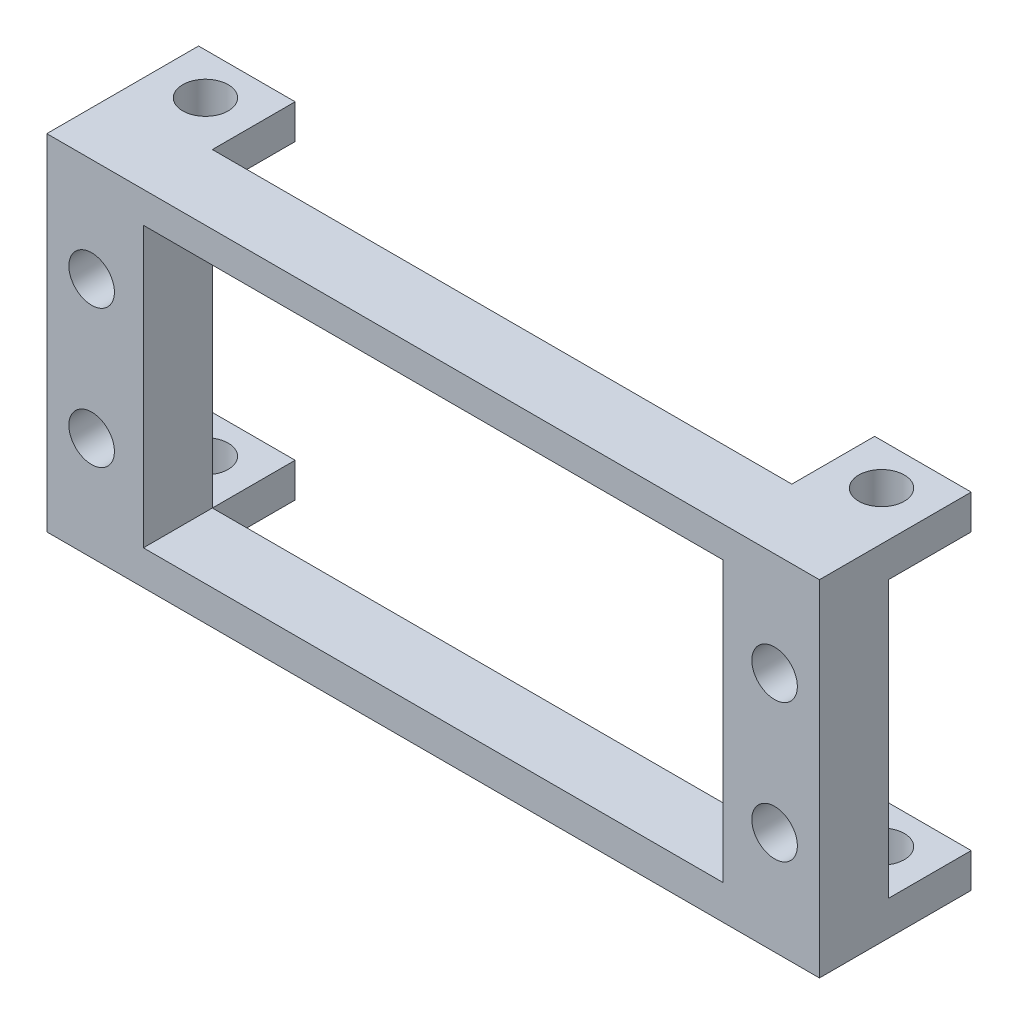
from build123d import *

# Parameters (mm, degrees)
SKETCH1_W                           = 56
SKETCH1_H                           = 25
SKETCH1_W_2                         = 42
SKETCH1_H_2                         = 20.25
EXTRUDE1_DEPTH                      = 5
M4X0_7_TAPPED_HOLE1_D               = 3.3
SKETCH7_W                           = 7
SKETCH7_H                           = 2.5
EXTRUDE5_DEPTH                      = 6
M4X0_7_TAPPED_HOLE2_D               = 3.3
M4X0_7_TAPPED_HOLE2_DEPTH           = 10.3
M4X0_7_TAPPED_HOLE2_TIP             = 0.991420021
M4X0_7_TAPPED_HOLE2_ON_FACE_2_D     = 3.3
M4X0_7_TAPPED_HOLE2_ON_FACE_2_DEPTH = 10.3
M4X0_7_TAPPED_HOLE2_ON_FACE_2_TIP   = 0.991420021


with BuildPart() as part:
    # Sketch1 → Extrude1 (new body)
    with BuildSketch(Plane.XY):
        with Locations((-28, 12.5)):
            Rectangle(SKETCH1_W, SKETCH1_H)
        with Locations((-28, 12.625)):
            Rectangle(SKETCH1_W_2, SKETCH1_H_2, mode=Mode.SUBTRACT)
    extrude(amount=EXTRUDE1_DEPTH)

    # M4x0.7 Tapped Hole1 (through all)
    with Locations(Plane(origin=(-52.75, 17.5, 5), x_dir=(1, 0, 0), z_dir=(0, 0, 1))):
        with Locations((0, 0), (0, -10), (49.5, -10), (49.5, 0)):
            Hole(M4X0_7_TAPPED_HOLE1_D / 2)

    # Sketch7 → Extrude5 (add)
    with BuildSketch(Plane(origin=(0, 0, 0), x_dir=(-1, 0, 0), z_dir=(0, 0, -1))):
        with Locations((3.5, 23.75)):
            Rectangle(SKETCH7_W, SKETCH7_H)
        with Locations((3.5, 1.25)):
            Rectangle(SKETCH7_W, SKETCH7_H)
        with Locations((52.5, 1.25)):
            Rectangle(SKETCH7_W, SKETCH7_H)
        with Locations((52.5, 23.75)):
            Rectangle(SKETCH7_W, SKETCH7_H)
    extrude(amount=EXTRUDE5_DEPTH)

    # M4x0.7 Tapped Hole2
    with Locations(Plane(origin=(-3.5, 25, -3), x_dir=(0, 0, 1), z_dir=(0, 1, 0))):
        with Locations((0, 0), (0, -49)):
            Hole(M4X0_7_TAPPED_HOLE2_D / 2, depth=M4X0_7_TAPPED_HOLE2_DEPTH)
            with Locations((0, 0, -(M4X0_7_TAPPED_HOLE2_DEPTH + M4X0_7_TAPPED_HOLE2_TIP / 2))):  # 118° drill point
                Cone(0, M4X0_7_TAPPED_HOLE2_D / 2, M4X0_7_TAPPED_HOLE2_TIP, mode=Mode.SUBTRACT)

    # M4x0.7 Tapped Hole2 on face 2
    with Locations(Plane(origin=(-3.5, 0, -3), x_dir=(0, 0, -1), z_dir=(0, -1, 0))):
        with Locations((0, 0), (0, -49)):
            Hole(M4X0_7_TAPPED_HOLE2_ON_FACE_2_D / 2, depth=M4X0_7_TAPPED_HOLE2_ON_FACE_2_DEPTH)
            with Locations((0, 0, -(M4X0_7_TAPPED_HOLE2_ON_FACE_2_DEPTH + M4X0_7_TAPPED_HOLE2_ON_FACE_2_TIP / 2))):  # 118° drill point
                Cone(0, M4X0_7_TAPPED_HOLE2_ON_FACE_2_D / 2, M4X0_7_TAPPED_HOLE2_ON_FACE_2_TIP, mode=Mode.SUBTRACT)


solid = part.part
